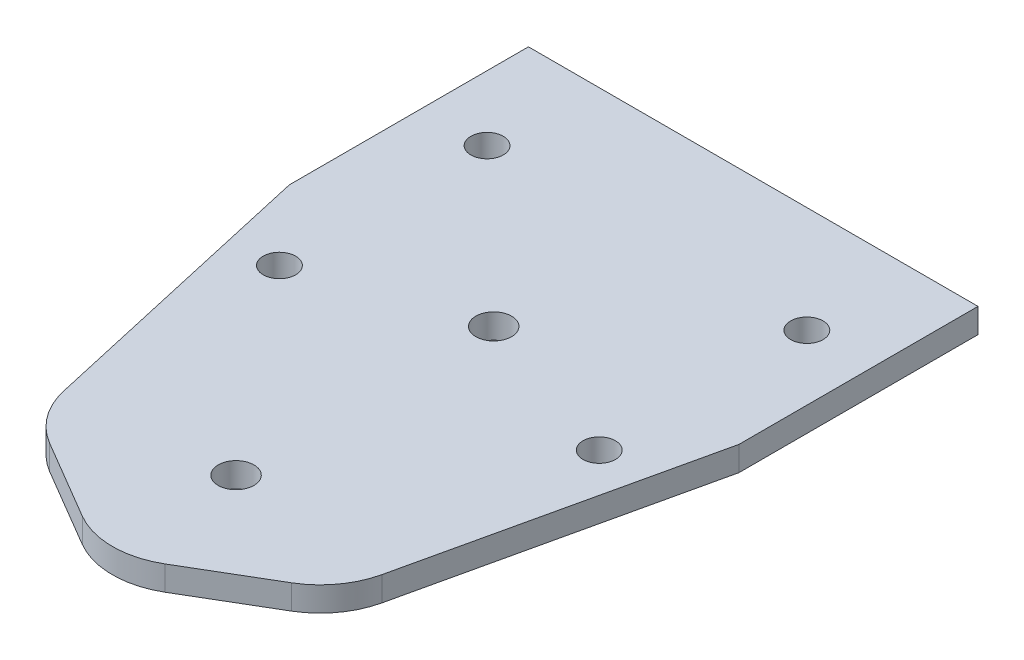
from build123d import *

# Parameters (mm, degrees)
SKETCH1_W           = 55
SKETCH1_H           = 80
BOSS_EXTRUDE1_DEPTH = 3
SKETCH2_R           = 2.185
SKETCH2_R_2         = 1.984375
CUT_EXTRUDE1_DEPTH  = 4
CUT_EXTRUDE2_DEPTH  = 4
FILLET1_R           = 10


with BuildPart() as part:
    # Sketch1 → Boss-Extrude1 (new body)
    with BuildSketch(Plane(origin=(0, 0, 0), x_dir=(1, 0, 0), z_dir=(0, 1, 0))):
        Rectangle(SKETCH1_W, SKETCH1_H)
    extrude(amount=BOSS_EXTRUDE1_DEPTH)

    # Sketch2 → Cut-Extrude1 (cut, through all)
    with BuildSketch(Plane(origin=(0, 3, 0), x_dir=(1, 0, 0), z_dir=(0, 1, 0))):
        with Locations((0, 8.25)):
            Circle(SKETCH2_R)
        with Locations((0, -23.271)):
            Circle(SKETCH2_R)
        with Locations((-19.5625, 27)):
            Circle(SKETCH2_R_2)
        with Locations((-19.5625, 1.6)):
            Circle(SKETCH2_R_2)
        with Locations((19.5625, 27)):
            Circle(SKETCH2_R_2)
        with Locations((19.5625, 1.6)):
            Circle(SKETCH2_R_2)
    extrude(amount=-CUT_EXTRUDE1_DEPTH, mode=Mode.SUBTRACT)

    # Sketch3 → Cut-Extrude2 (cut, through all)
    with BuildSketch(Plane(origin=(0, 3, 0), x_dir=(1, 0, 0), z_dir=(0, 1, 0))):
        Polygon((18.510308796, -29.09449619), (0, -40), (27.5, -40), (27.5, 10.752872816), align=None)
    cut_extrude2 = extrude(amount=-CUT_EXTRUDE2_DEPTH, mode=Mode.SUBTRACT)

    # Mirror1: Cut-Extrude2 across plane
    add(cut_extrude2.mirror(Plane(origin=(0, 0, 0), x_dir=(0, 0, 1), z_dir=(1, 0, 0))), mode=Mode.SUBTRACT)

    # Fillet1
    fillet1_edges = [part.edges().sort_by_distance(p)[0] for p in [
        (18.510308796, 1.5, 29.09449619),
        (0, 1.5, 40),
        (-18.510308796, 1.5, 29.09449619),
    ]]
    fillet(fillet1_edges, radius=FILLET1_R)


solid = part.part
